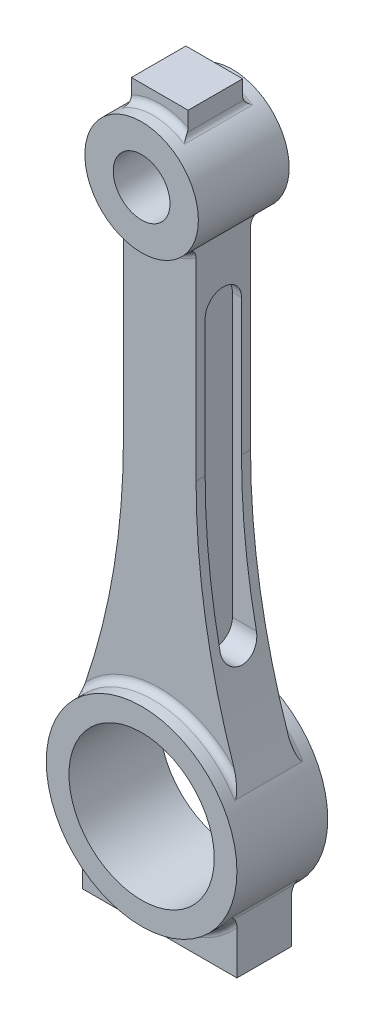
from build123d import *

# Parameters (mm, degrees)
SKETCH1_R             = 533.4
SKETCH1_R_2           = 406.4
BOSS_EXTRUDE1_DEPTH   = 254
SKETCH1_R_3           = 317.5
SKETCH1_R_4           = 158.75
BOSS_EXTRUDE1_2_DEPTH = 254
BOSS_EXTRUDE3_DEPTH   = 152.4
BOSS_EXTRUDE4_DEPTH   = 152.4
FILLET1_R             = 38.1
FILLET2_R             = 38.1
FILLET3_R             = 38.1
CUT_EXTRUDE2_DEPTH    = 1331.976


with BuildPart() as part:
    # Sketch1 → Boss-Extrude1 (new body, symmetric)
    with BuildSketch(Plane.XY):
        Circle(SKETCH1_R)
        Circle(SKETCH1_R_2, mode=Mode.SUBTRACT)
    extrude(amount=BOSS_EXTRUDE1_DEPTH, both=True)



with BuildPart() as body_2:
    # Sketch1 → Boss-Extrude1 2 (new body, symmetric)
    with BuildSketch(Plane.XY):
        with Locations((0, 3048)):
            Circle(SKETCH1_R_3)
        with Locations((0, 3048)):
            Circle(SKETCH1_R_4, mode=Mode.SUBTRACT)
    extrude(amount=BOSS_EXTRUDE1_2_DEPTH, both=True)


with BuildPart() as part_1:
    add(part.part)

    add(body_2.part)  # Boss-Extrude3 merges body 2
    # Sketch3 → Boss-Extrude3 (add, symmetric)
    with BuildSketch(Plane.XY):
        with BuildLine():
            Line((203.2, 1675.01897356), (203.2, 2804.040966554))
            ThreePointArc((203.2, 2804.040966554), (0, 2730.5), (-203.2, 2804.040966554))
            Line((-203.2, 2804.040966554), (-203.2, 1675.01897356))
            ThreePointArc((-203.2, 1675.01897356), (-267.2957105, 963.163972593), (-457.520992032, 274.208136003))
            ThreePointArc((-457.520992032, 274.208136003), (0, 533.4), (457.520992032, 274.208136003))
            ThreePointArc((457.520992032, 274.208136003), (267.2957105, 963.163972593), (203.2, 1675.01897356))
        make_face()
    extrude(amount=BOSS_EXTRUDE3_DEPTH, both=True)

    # Sketch6 → Boss-Extrude4 (add, symmetric)
    with BuildSketch(Plane.XY):
        with BuildLine():
            Line((-158.75, 3449.963065702), (-158.75, 3322.963065702))
            ThreePointArc((-158.75, 3322.963065702), (0, 3365.5), (158.75, 3322.963065702))
            Line((158.75, 3322.963065702), (158.75, 3449.963065702))
            Line((158.75, 3449.963065702), (-158.75, 3449.963065702))
        make_face()
        with BuildLine():
            Line((-431.8, -617.952231351), (-431.8, -313.152231351))
            ThreePointArc((-431.8, -313.152231351), (0, -533.4), (431.8, -313.152231351))
            Line((431.8, -313.152231351), (431.8, -617.952231351))
            Line((431.8, -617.952231351), (-431.8, -617.952231351))
        make_face()
    extrude(amount=BOSS_EXTRUDE4_DEPTH, both=True)

    # Fillet1
    fillet1_edges = [part_1.edges().sort_by_distance(p)[0] for p in [
        (158.75, 3322.963065702, 0),
        (0, 3365.5, 152.4),
        (-158.75, 3322.963065702, 0),
        (0, 3365.5, -152.4),
    ]]
    fillet(fillet1_edges, radius=FILLET1_R)

    # Fillet2
    fillet2_edges = [part_1.edges().sort_by_distance(p)[0] for p in [
        (0, 2730.5, 152.4),
        (0, 533.4, 152.4),
        (0, 2730.5, -152.4),
        (0, 533.4, -152.4),
    ]]
    fillet(fillet2_edges, radius=FILLET2_R)

    # Fillet3
    fillet3_edges = [part_1.edges().sort_by_distance(p)[0] for p in [
        (-431.8, -313.152231351, 0),
        (0, -533.4, 152.4),
        (431.8, -313.152231351, 0),
        (0, -533.4, -152.4),
    ]]
    fillet(fillet3_edges, radius=FILLET3_R)

    # Sketch7 → Cut-Extrude2 (cut)
    with BuildSketch(Plane(origin=(152.4, 0, 0), x_dir=(0, 0, -1), z_dir=(1, 0, 0))):
        with BuildLine():
            Line((101.6, 2438.4), (101.6, 863.6))
            ThreePointArc((101.6, 863.6), (0, 762), (-101.6, 863.6))
            Line((-101.6, 863.6), (-101.6, 2438.4))
            ThreePointArc((-101.6, 2438.4), (0, 2540), (101.6, 2438.4))
        make_face()
    cut_extrude2 = extrude(amount=CUT_EXTRUDE2_DEPTH, mode=Mode.SUBTRACT)

    # Mirror1: Cut-Extrude2 across plane
    add(cut_extrude2.mirror(Plane(origin=(0, 0, 0), x_dir=(0, 0, 1), z_dir=(1, 0, 0))), mode=Mode.SUBTRACT)


solid = part_1.part
